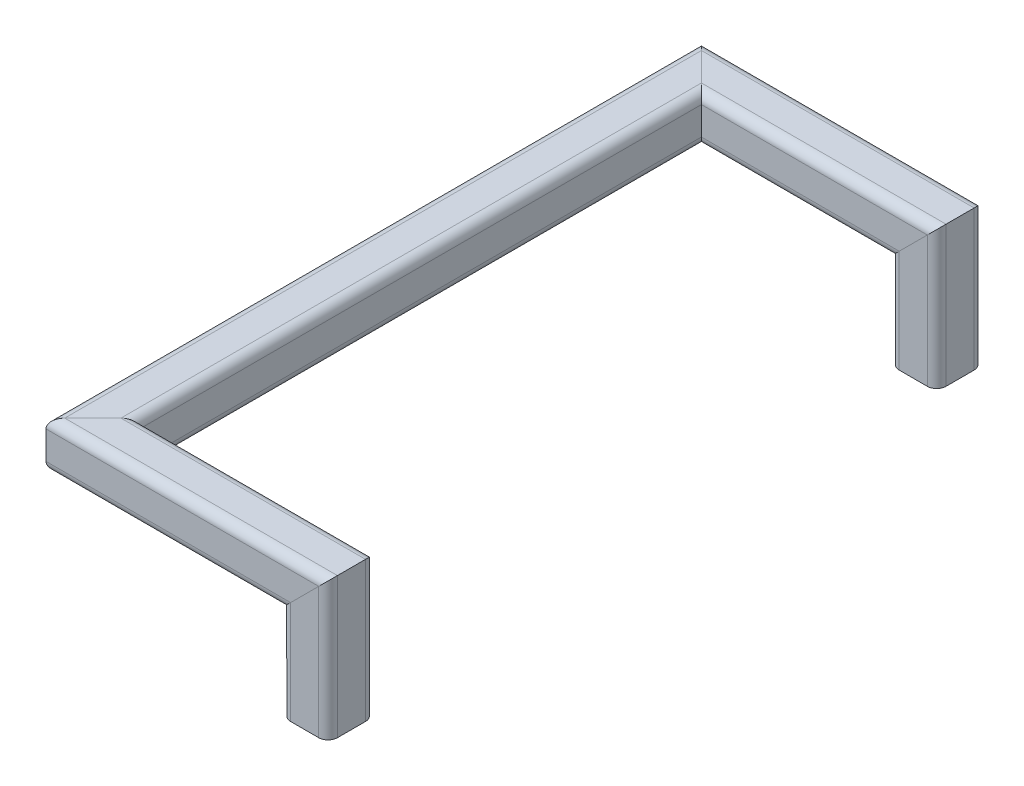
from build123d import *

# Parameters (mm, degrees)
SQUARE_TUBING_1_X_1_X_0_125_1_DEPTH        = 82.460512242
SQUARE_TUBING_1_X_1_X_0_125_1_2_DEPTH      = 165.556024484
SQUARE_TUBING_1_X_1_X_0_125_1_3_DEPTH      = 368.121024484
SQUARE_TUBING_1_X_1_X_0_125_1_4_DEPTH      = 146.595512242
SQUARE_TUBING_1_X_1_X_0_125_1_4_DEPTH_BACK = 18.960512242
SQUARE_TUBING_1_X_1_X_0_125_1_5_DEPTH      = 82.460512242


with BuildPart() as part:
    # Sketch1 on segment 1 (carried to segment 1) → Square tubing 1 X 1 X 0.125(1) (new body)
    with BuildSketch(Plane(origin=(127.635, -63.5, -330.2), x_dir=(0, 0, -1), z_dir=(0, 1, 0))):
        with BuildLine():
            Line((-7.62, -12.7), (7.62, -12.7))
            ThreePointArc((7.62, -12.7), (11.212102448, -11.212102448), (12.7, -7.62))
            Line((12.7, -7.62), (12.7, 7.62))
            ThreePointArc((12.7, 7.62), (11.212102448, 11.212102448), (7.62, 12.7))
            Line((7.62, 12.7), (-7.62, 12.7))
            ThreePointArc((-7.62, 12.7), (-11.212102448, 11.212102448), (-12.7, 7.62))
            Line((-12.7, 7.62), (-12.7, -7.62))
            ThreePointArc((-12.7, -7.62), (-11.212102448, -11.212102448), (-7.62, -12.7))
        make_face()
        with BuildLine():
            Line((-7.62, -9.525), (7.62, -9.525))
            ThreePointArc((7.62, -9.525), (8.967038418, -8.967038418), (9.525, -7.62))
            Line((9.525, -7.62), (9.525, 7.62))
            ThreePointArc((9.525, 7.62), (8.967038418, 8.967038418), (7.62, 9.525))
            Line((7.62, 9.525), (-7.62, 9.525))
            ThreePointArc((-7.62, 9.525), (-8.967038418, 8.967038418), (-9.525, 7.62))
            Line((-9.525, 7.62), (-9.525, -7.62))
            ThreePointArc((-9.525, -7.62), (-8.967038418, -8.967038418), (-7.62, -9.525))
        make_face(mode=Mode.SUBTRACT)
    extrude(amount=SQUARE_TUBING_1_X_1_X_0_125_1_DEPTH)

    # Square tubing 1 X 1 X 0.125(1) mitre 1
    split(bisect_by=Plane(origin=(127.635, 0, -330.2), x_dir=(0.707106781, 0.707106781, 0), z_dir=(0.707106781, -0.707106781, 0)), keep=Keep.TOP)


with BuildPart() as body_2:
    # Sketch1 on segment 2 (carried to segment 2) → Square tubing 1 X 1 X 0.125_1 2 (new body)
    with BuildSketch(Plane(origin=(146.595512242, 0, -330.2), x_dir=(0, 0, 1), z_dir=(-1, 0, 0))):
        with BuildLine():
            Line((-7.62, -12.7), (7.62, -12.7))
            ThreePointArc((7.62, -12.7), (11.212102448, -11.212102448), (12.7, -7.62))
            Line((12.7, -7.62), (12.7, 7.62))
            ThreePointArc((12.7, 7.62), (11.212102448, 11.212102448), (7.62, 12.7))
            Line((7.62, 12.7), (-7.62, 12.7))
            ThreePointArc((-7.62, 12.7), (-11.212102448, 11.212102448), (-12.7, 7.62))
            Line((-12.7, 7.62), (-12.7, -7.62))
            ThreePointArc((-12.7, -7.62), (-11.212102448, -11.212102448), (-7.62, -12.7))
        make_face()
        with BuildLine():
            Line((-7.62, -9.525), (7.62, -9.525))
            ThreePointArc((7.62, -9.525), (8.967038418, -8.967038418), (9.525, -7.62))
            Line((9.525, -7.62), (9.525, 7.62))
            ThreePointArc((9.525, 7.62), (8.967038418, 8.967038418), (7.62, 9.525))
            Line((7.62, 9.525), (-7.62, 9.525))
            ThreePointArc((-7.62, 9.525), (-8.967038418, 8.967038418), (-9.525, 7.62))
            Line((-9.525, 7.62), (-9.525, -7.62))
            ThreePointArc((-9.525, -7.62), (-8.967038418, -8.967038418), (-7.62, -9.525))
        make_face(mode=Mode.SUBTRACT)
    extrude(amount=SQUARE_TUBING_1_X_1_X_0_125_1_2_DEPTH)

    # Square tubing 1 X 1 X 0.125_1 2 mitre 1
    split(bisect_by=Plane(origin=(0, 0, -330.2), x_dir=(0, 1, 0), z_dir=(0.707106781, 0, -0.707106781)), keep=Keep.TOP)

    # Square tubing 1 X 1 X 0.125_1 2 mitre 2
    split(bisect_by=Plane(origin=(127.635, 0, -330.2), x_dir=(-0.707106781, -0.707106781, 0), z_dir=(-0.707106781, 0.707106781, 0)), keep=Keep.TOP)


with BuildPart() as body_3:
    # Sketch1 on segment 3 (carried to segment 3) → Square tubing 1 X 1 X 0.125_1 3 (new body)
    with BuildSketch(Plane.XY.offset(-349.160512242)):
        with BuildLine():
            Line((-7.62, -12.7), (7.62, -12.7))
            ThreePointArc((7.62, -12.7), (11.212102448, -11.212102448), (12.7, -7.62))
            Line((12.7, -7.62), (12.7, 7.62))
            ThreePointArc((12.7, 7.62), (11.212102448, 11.212102448), (7.62, 12.7))
            Line((7.62, 12.7), (-7.62, 12.7))
            ThreePointArc((-7.62, 12.7), (-11.212102448, 11.212102448), (-12.7, 7.62))
            Line((-12.7, 7.62), (-12.7, -7.62))
            ThreePointArc((-12.7, -7.62), (-11.212102448, -11.212102448), (-7.62, -12.7))
        make_face()
        with BuildLine():
            Line((-7.62, -9.525), (7.62, -9.525))
            ThreePointArc((7.62, -9.525), (8.967038418, -8.967038418), (9.525, -7.62))
            Line((9.525, -7.62), (9.525, 7.62))
            ThreePointArc((9.525, 7.62), (8.967038418, 8.967038418), (7.62, 9.525))
            Line((7.62, 9.525), (-7.62, 9.525))
            ThreePointArc((-7.62, 9.525), (-8.967038418, 8.967038418), (-9.525, 7.62))
            Line((-9.525, 7.62), (-9.525, -7.62))
            ThreePointArc((-9.525, -7.62), (-8.967038418, -8.967038418), (-7.62, -9.525))
        make_face(mode=Mode.SUBTRACT)
    extrude(amount=SQUARE_TUBING_1_X_1_X_0_125_1_3_DEPTH)

    # Square tubing 1 X 1 X 0.125_1 3 mitre 1
    split(bisect_by=Plane(origin=(0, 0, 0), x_dir=(0, -1, 0), z_dir=(-0.707106781, 0, -0.707106781)), keep=Keep.TOP)

    # Square tubing 1 X 1 X 0.125_1 3 mitre 2
    split(bisect_by=Plane(origin=(0, 0, -330.2), x_dir=(0, -1, 0), z_dir=(-0.707106781, 0, 0.707106781)), keep=Keep.TOP)


with BuildPart() as body_4:
    # Sketch1 → Square tubing 1 X 1 X 0.125_1 4 (new, two sides)
    with BuildSketch(Plane(origin=(0, 0, 0), x_dir=(0, 0, -1), z_dir=(1, 0, 0))) as square_tubing_1_x_1_x_0_125_1_4_sk:
        with BuildLine():
            Line((-7.62, -12.7), (7.62, -12.7))
            ThreePointArc((7.62, -12.7), (11.212102448, -11.212102448), (12.7, -7.62))
            Line((12.7, -7.62), (12.7, 7.62))
            ThreePointArc((12.7, 7.62), (11.212102448, 11.212102448), (7.62, 12.7))
            Line((7.62, 12.7), (-7.62, 12.7))
            ThreePointArc((-7.62, 12.7), (-11.212102448, 11.212102448), (-12.7, 7.62))
            Line((-12.7, 7.62), (-12.7, -7.62))
            ThreePointArc((-12.7, -7.62), (-11.212102448, -11.212102448), (-7.62, -12.7))
        make_face()
        with BuildLine():
            Line((-7.62, -9.525), (7.62, -9.525))
            ThreePointArc((7.62, -9.525), (8.967038418, -8.967038418), (9.525, -7.62))
            Line((9.525, -7.62), (9.525, 7.62))
            ThreePointArc((9.525, 7.62), (8.967038418, 8.967038418), (7.62, 9.525))
            Line((7.62, 9.525), (-7.62, 9.525))
            ThreePointArc((-7.62, 9.525), (-8.967038418, 8.967038418), (-9.525, 7.62))
            Line((-9.525, 7.62), (-9.525, -7.62))
            ThreePointArc((-9.525, -7.62), (-8.967038418, -8.967038418), (-7.62, -9.525))
        make_face(mode=Mode.SUBTRACT)
    extrude(amount=SQUARE_TUBING_1_X_1_X_0_125_1_4_DEPTH)
    extrude(square_tubing_1_x_1_x_0_125_1_4_sk.sketch, amount=-SQUARE_TUBING_1_X_1_X_0_125_1_4_DEPTH_BACK)

    # Square tubing 1 X 1 X 0.125_1 4 mitre 1
    split(bisect_by=Plane(origin=(0, 0, 0), x_dir=(0, 1, 0), z_dir=(0.707106781, 0, 0.707106781)), keep=Keep.TOP)

    # Square tubing 1 X 1 X 0.125_1 4 mitre 2
    split(bisect_by=Plane(origin=(127.635, 0, 0), x_dir=(-0.707106781, -0.707106781, 0), z_dir=(-0.707106781, 0.707106781, 0)), keep=Keep.TOP)


with BuildPart() as body_5:
    # Sketch1 on segment 5 (carried to segment 5) → Square tubing 1 X 1 X 0.125_1 5 (new body)
    with BuildSketch(Plane(origin=(127.635, 18.960512242, 0), x_dir=(0, 0, -1), z_dir=(0, -1, 0))):
        with BuildLine():
            Line((-7.62, -12.7), (7.62, -12.7))
            ThreePointArc((7.62, -12.7), (11.212102448, -11.212102448), (12.7, -7.62))
            Line((12.7, -7.62), (12.7, 7.62))
            ThreePointArc((12.7, 7.62), (11.212102448, 11.212102448), (7.62, 12.7))
            Line((7.62, 12.7), (-7.62, 12.7))
            ThreePointArc((-7.62, 12.7), (-11.212102448, 11.212102448), (-12.7, 7.62))
            Line((-12.7, 7.62), (-12.7, -7.62))
            ThreePointArc((-12.7, -7.62), (-11.212102448, -11.212102448), (-7.62, -12.7))
        make_face()
        with BuildLine():
            Line((-7.62, -9.525), (7.62, -9.525))
            ThreePointArc((7.62, -9.525), (8.967038418, -8.967038418), (9.525, -7.62))
            Line((9.525, -7.62), (9.525, 7.62))
            ThreePointArc((9.525, 7.62), (8.967038418, 8.967038418), (7.62, 9.525))
            Line((7.62, 9.525), (-7.62, 9.525))
            ThreePointArc((-7.62, 9.525), (-8.967038418, 8.967038418), (-9.525, 7.62))
            Line((-9.525, 7.62), (-9.525, -7.62))
            ThreePointArc((-9.525, -7.62), (-8.967038418, -8.967038418), (-7.62, -9.525))
        make_face(mode=Mode.SUBTRACT)
    extrude(amount=SQUARE_TUBING_1_X_1_X_0_125_1_5_DEPTH)

    # Square tubing 1 X 1 X 0.125_1 5 mitre 1
    split(bisect_by=Plane(origin=(127.635, 0, 0), x_dir=(0.707106781, 0.707106781, 0), z_dir=(0.707106781, -0.707106781, 0)), keep=Keep.TOP)


solid = Compound([part.part, body_2.part, body_3.part, body_4.part, body_5.part])
